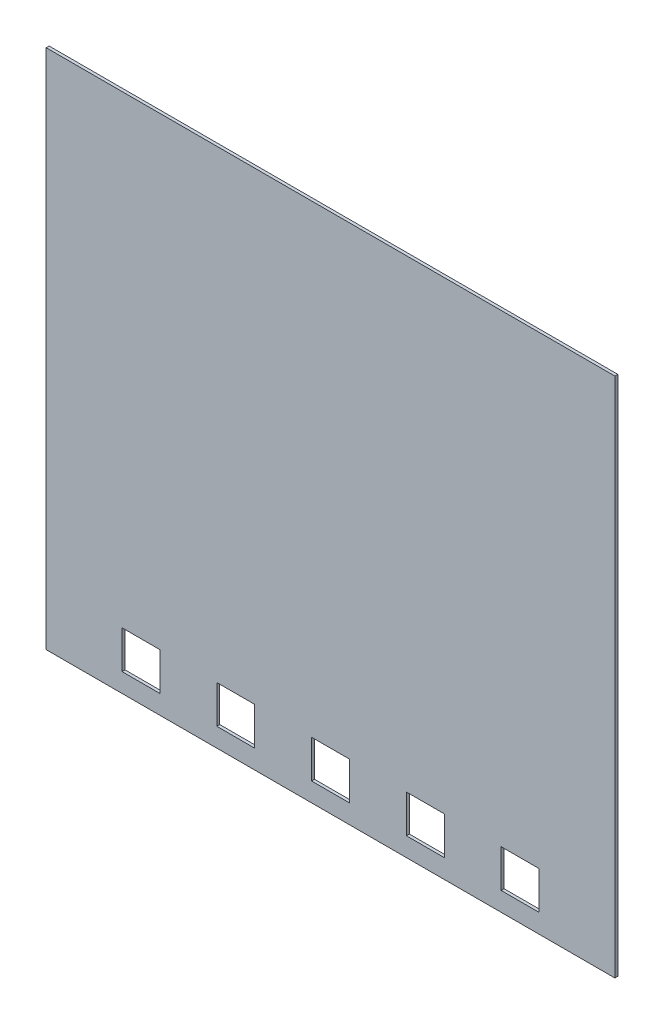
from build123d import *

# Parameters (mm, degrees)
SKETCH1_W           = 76.2
SKETCH1_H           = 69.85
BOSS_EXTRUDE1_DEPTH = 0.396875
SKETCH2_W           = 5.08
SKETCH2_H           = 5.08
CUT_EXTRUDE1_DEPTH  = 1.396875


with BuildPart() as part:
    # Sketch1 → Boss-Extrude1 (new body)
    with BuildSketch(Plane.XY):
        with Locations((-38.1, 34.925)):
            Rectangle(SKETCH1_W, SKETCH1_H)
    extrude(amount=BOSS_EXTRUDE1_DEPTH)

    # Sketch2 → Cut-Extrude1 (cut, through all)
    with BuildSketch(Plane(origin=(0, 0, 0), x_dir=(-1, 0, 0), z_dir=(0, 0, -1))):
        with Locations((63.5, 5.08)):
            Rectangle(SKETCH2_W, SKETCH2_H)
        with Locations((50.8, 5.08)):
            Rectangle(SKETCH2_W, SKETCH2_H)
        with Locations((38.1, 5.08)):
            Rectangle(SKETCH2_W, SKETCH2_H)
        with Locations((25.4, 5.08)):
            Rectangle(SKETCH2_W, SKETCH2_H)
        with Locations((12.7, 5.08)):
            Rectangle(SKETCH2_W, SKETCH2_H)
    extrude(amount=-CUT_EXTRUDE1_DEPTH, mode=Mode.SUBTRACT)


solid = part.part
